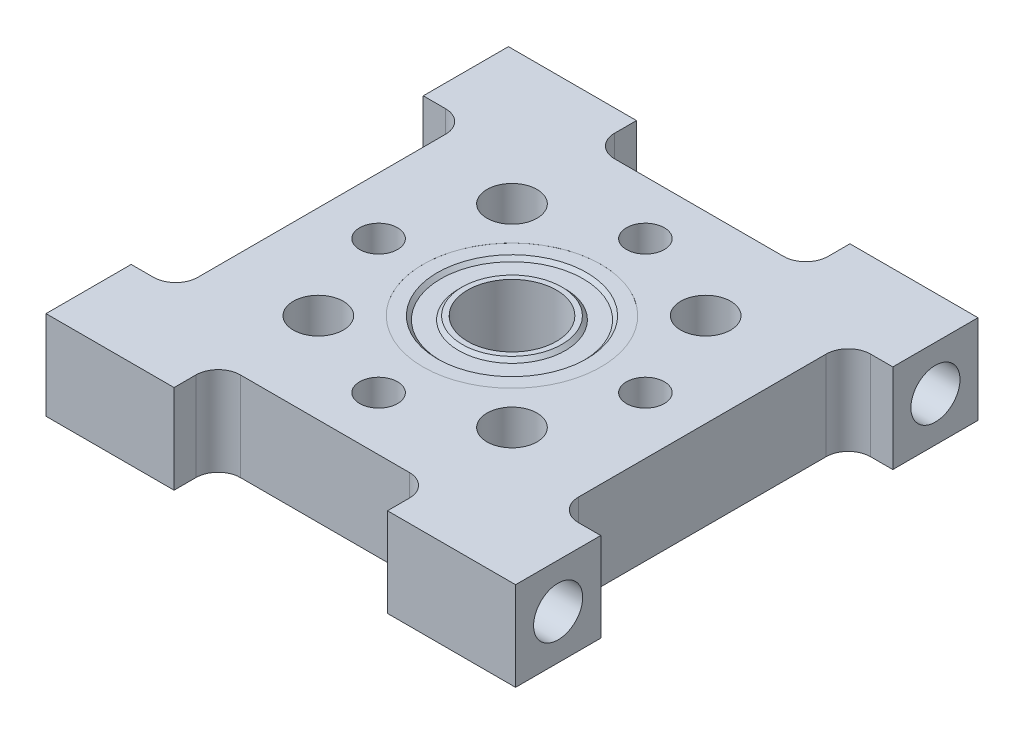
from build123d import *

# Parameters (mm, degrees)
SKETCH1_R                           = 5.3975
BOSS_EXTRUDE1_DEPTH                 = 6.35
SKETCH2_R                           = 6.35
CUT_EXTRUDE1_DEPTH                  = 4.7625
SKETCH3_R                           = 6.35
SKETCH3_R_2                         = 5.08
BOSS_EXTRUDE2_DEPTH                 = 4.75996
CHAMFER1_SIZE                       = 0.254
SKETCH4_R                           = 3.81
SKETCH4_R_2                         = 3.175
BOSS_EXTRUDE3_DEPTH                 = 4.75996
CHAMFER2_SIZE                       = 0.254
SKETCH5_R                           = 5.08
SKETCH5_R_2                         = 3.81
BOSS_EXTRUDE4_DEPTH                 = 4.2545
F_6_32_TAPPED_HOLE1_AT_2_COUNT      = 2
F_6_32_TAPPED_HOLE1_AT_2_PITCH      = 26.940768363
F_6_32_TAPPED_HOLE2_D               = 2.7051
F_6_32_TAPPED_HOLE2_DEPTH           = 6.35
F_9_64_0_14063_DIAMETER_HOLE1_D     = 3.572002
F_9_64_0_14063_DIAMETER_HOLE1_DEPTH = 6.35
F_9_64_0_14063_DIAMETER_HOLE1_TIP   = 1.073137666


with BuildPart() as part:
    # Sketch1 → Boss-Extrude1 (new body)
    with BuildSketch(Plane(origin=(0, 0, 0), x_dir=(1, 0, 0), z_dir=(0, 1, 0))):
        with BuildLine():
            Line((-16.764, -16.51), (-7.62, -16.51))
            Line((-7.62, -16.51), (-7.62, -14.9479))
            ThreePointArc((-7.62, -14.9479), (-7.155032015, -13.825367985), (-6.0325, -13.3604))
            Line((-6.0325, -13.3604), (6.0325, -13.3604))
            ThreePointArc((6.0325, -13.3604), (7.155032015, -13.825367985), (7.62, -14.9479))
            Line((7.62, -14.9479), (7.62, -16.51))
            Line((7.62, -16.51), (16.764, -16.51))
            Line((16.764, -16.51), (16.764, -10.4267))
            Line((16.764, -10.4267), (15.1765, -10.4267))
            ThreePointArc((15.1765, -10.4267), (14.053967985, -9.961732015), (13.589, -8.8392))
            Line((13.589, -8.8392), (13.589, 8.8392))
            ThreePointArc((13.589, 8.8392), (14.053967985, 9.961732015), (15.1765, 10.4267))
            Line((15.1765, 10.4267), (16.764, 10.4267))
            Line((16.764, 10.4267), (16.764, 16.51))
            Line((16.764, 16.51), (7.62, 16.51))
            Line((7.62, 16.51), (7.62, 14.9479))
            ThreePointArc((7.62, 14.9479), (7.155032015, 13.825367985), (6.0325, 13.3604))
            Line((6.0325, 13.3604), (-6.0325, 13.3604))
            ThreePointArc((-6.0325, 13.3604), (-7.155032015, 13.825367985), (-7.62, 14.9479))
            Line((-7.62, 14.9479), (-7.62, 16.51))
            Line((-7.62, 16.51), (-16.764, 16.51))
            Line((-16.764, 16.51), (-16.764, 10.4267))
            Line((-16.764, 10.4267), (-15.1765, 10.4267))
            ThreePointArc((-15.1765, 10.4267), (-14.053967985, 9.961732015), (-13.589, 8.8392))
            Line((-13.589, 8.8392), (-13.589, -8.8392))
            ThreePointArc((-13.589, -8.8392), (-14.053967985, -9.961732015), (-15.1765, -10.4267))
            Line((-15.1765, -10.4267), (-16.764, -10.4267))
            Line((-16.764, -10.4267), (-16.764, -16.51))
        make_face()
        Circle(SKETCH1_R, mode=Mode.SUBTRACT)
    extrude(amount=BOSS_EXTRUDE1_DEPTH)

    # Sketch2 → Cut-Extrude1 (cut)
    with BuildSketch(Plane(origin=(0, 6.35, 0), x_dir=(1, 0, 0), z_dir=(0, 1, 0))):
        Circle(SKETCH2_R)
    extrude(amount=-CUT_EXTRUDE1_DEPTH, mode=Mode.SUBTRACT)

    # Sketch3 → Boss-Extrude2 (add)
    with BuildSketch(Plane(origin=(0, 1.5875, 0), x_dir=(-1, 0, 0), z_dir=(0, 1, 0))):
        Circle(SKETCH3_R)
        Circle(SKETCH3_R_2, mode=Mode.SUBTRACT)
    extrude(amount=BOSS_EXTRUDE2_DEPTH)

    # Chamfer1
    chamfer1_edges = [part.edges().sort_by_distance(p)[0] for p in [
        (5.08, 1.5875, 0),
        (5.08, 6.34746, 0),
    ]]
    chamfer(chamfer1_edges, length=CHAMFER1_SIZE)



with BuildPart() as body_2:
    # Sketch4 → Boss-Extrude3 (new body)
    with BuildSketch(Plane(origin=(0, 1.5875, 0), x_dir=(-1, 0, 0), z_dir=(0, 1, 0))):
        Circle(SKETCH4_R)
        Circle(SKETCH4_R_2, mode=Mode.SUBTRACT)
    extrude(amount=BOSS_EXTRUDE3_DEPTH)

    # Chamfer2
    chamfer2_edges = [body_2.edges().sort_by_distance(p)[0] for p in [
        (3.81, 1.5875, 0),
        (3.81, 6.34746, 0),
    ]]
    chamfer(chamfer2_edges, length=CHAMFER2_SIZE)


with BuildPart() as part_1:
    add(part.part)

    add(body_2.part)  # Boss-Extrude4 merges body 2
    # Sketch5 → Boss-Extrude4 (add)
    with BuildSketch(Plane(origin=(0, 6.09346, 0), x_dir=(-1, 0, 0), z_dir=(0, 1, 0))):
        Circle(SKETCH5_R)
        Circle(SKETCH5_R_2, mode=Mode.SUBTRACT)
    extrude(amount=-BOSS_EXTRUDE4_DEPTH)

    # Sketch8 → #6-32 Tapped Hole1 (revolve, cut)
    with BuildSketch(Plane(origin=(-16.764, 3.175, -13.470384182), x_dir=(0, 0, 1), z_dir=(0, 1, 0))):
        Polygon((0, 0), (0, 8.76289403), (1.35255, 7.9502), (1.35255, 7.0104), (1.7526, 7.0104), (1.7526, 0), align=None)
    f_6_32_tapped_hole1 = revolve(axis=Axis((-23.114, 3.175, -13.470384182), (1, 0, 0)), mode=Mode.SUBTRACT)

    # #6-32 Tapped Hole1 at 2: #6-32 Tapped Hole1 ×2
    with Locations(*[(0, 0, i * F_6_32_TAPPED_HOLE1_AT_2_PITCH) for i in range(1, F_6_32_TAPPED_HOLE1_AT_2_COUNT)]):
        add(f_6_32_tapped_hole1, mode=Mode.SUBTRACT)

    # Mirror1: #6-32 Tapped Hole1 across plane
    add(f_6_32_tapped_hole1.mirror(Plane(origin=(0, 0, 0), x_dir=(0, 0, 1), z_dir=(1, 0, 0))), mode=Mode.SUBTRACT)

    # Mirror1 copy 1 sketch → Mirror1 copy 1 (revolve, cut)
    with BuildSketch(Plane(origin=(16.764, 3.175, 13.470384182), x_dir=(0, 0, 1), z_dir=(0, 1, 0))):
        Polygon((0, 0), (0, -8.76289403), (1.35255, -7.9502), (1.35255, -7.0104), (1.7526, -7.0104), (1.7526, 0), align=None)
    revolve(axis=Axis((23.114, 3.175, 13.470384182), (1, 0, 0)), mode=Mode.SUBTRACT)

    # #6-32 Tapped Hole2
    with Locations(Plane(origin=(0, 6.35, 0), x_dir=(-1, 0, 0), z_dir=(0, 1, 0))):
        with Locations((0, -9.525), (-9.525, 0), (0, 9.525), (9.525, 0)):
            Hole(F_6_32_TAPPED_HOLE2_D / 2, depth=F_6_32_TAPPED_HOLE2_DEPTH)

    # 9/64 (0.14063) Diameter Hole1
    with Locations(Plane(origin=(0, 6.35, 0), x_dir=(-1, 0, 0), z_dir=(0, 1, 0))):
        with Locations((6.914797213, -6.914797213), (-6.914797213, -6.914797213), (-6.914797213, 6.914797213), (6.914797213, 6.914797213)):
            Hole(F_9_64_0_14063_DIAMETER_HOLE1_D / 2, depth=F_9_64_0_14063_DIAMETER_HOLE1_DEPTH)
            with Locations((0, 0, -(F_9_64_0_14063_DIAMETER_HOLE1_DEPTH + F_9_64_0_14063_DIAMETER_HOLE1_TIP / 2))):  # 118° drill point
                Cone(0, F_9_64_0_14063_DIAMETER_HOLE1_D / 2, F_9_64_0_14063_DIAMETER_HOLE1_TIP, mode=Mode.SUBTRACT)


solid = part_1.part
